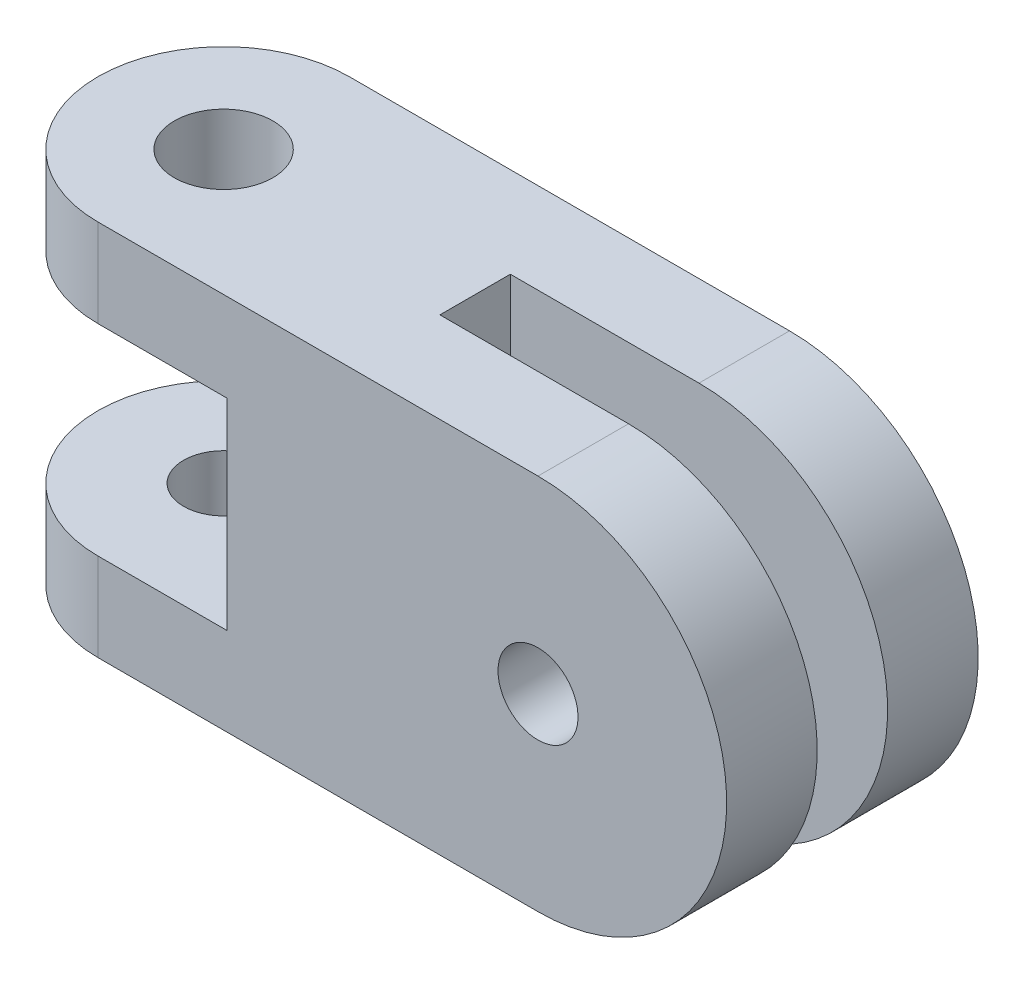
from build123d import *

# Parameters (mm, degrees)
BOSS_EXTRUDE1_DEPTH        = 9.525
BOSS_EXTRUDE2_DEPTH        = 12.7
CUT_EXTRUDE1_DEPTH         = 5.08
F_10_32_TAPPED_HOLE1_D     = 4.0386
F_10_32_TAPPED_HOLE1_DEPTH = 4.445
F_10_CLEARANCE_HOLE1_D     = 4.9784
F_10_CLEARANCE_HOLE1_DEPTH = 14.604
CUT_EXTRUDE2_DEPTH         = 1.778
F_10_CLEARANCE_HOLE2_D     = 4.9784
F_10_CLEARANCE_HOLE2_DEPTH = 8.127
F_10_32_TAPPED_HOLE2_D     = 4.0386


with BuildPart() as part:
    # Sketch1 → Boss-Extrude1 (new, symmetric)
    with BuildSketch(Plane(origin=(0, 0, 0), x_dir=(1, 0, 0), z_dir=(0, 1, 0))):
        with BuildLine():
            Line((0, -6.35), (-15.875, -6.35))
            ThreePointArc((-15.875, -6.35), (-22.225, 0), (-15.875, 6.35))
            Line((-15.875, 6.35), (0, 6.35))
            Line((0, 6.35), (0, -6.35))
        make_face()
    extrude(amount=BOSS_EXTRUDE1_DEPTH, both=True)

    # Sketch2 → Boss-Extrude2 (add)
    with BuildSketch(Plane.XY.offset(6.35)):
        with BuildLine():
            Line((0, 9.525), (6.35, 9.525))
            ThreePointArc((6.35, 9.525), (15.875, 0), (6.35, -9.525))
            Line((6.35, -9.525), (0, -9.525))
            ThreePointArc((0, -9.525), (-9.525, 0), (0, 9.525))
        make_face()
    extrude(amount=-BOSS_EXTRUDE2_DEPTH)

    # Sketch3 → Cut-Extrude1 (cut, symmetric)
    with BuildSketch(Plane(origin=(0, 0, 0), x_dir=(1, 0, 0), z_dir=(0, 1, 0))):
        with BuildLine():
            Line((-9.351499966, 6.35), (-15.875, 6.35))
            ThreePointArc((-15.875, 6.35), (-22.225, 0), (-15.875, -6.35))
            Line((-15.875, -6.35), (-9.351499966, -6.35))
            Line((-9.351499966, -6.35), (-9.351499966, 6.35))
        make_face()
    extrude(amount=CUT_EXTRUDE1_DEPTH, both=True, mode=Mode.SUBTRACT)

    # #10-32 Tapped Hole1
    with Locations(Plane(origin=(0, -5.08, 0), x_dir=(1, 0, 0), z_dir=(0, 1, 0))):
        with Locations((-15.875, 0)):
            Hole(F_10_32_TAPPED_HOLE1_D / 2, depth=F_10_32_TAPPED_HOLE1_DEPTH)

    # #10 Clearance Hole1
    with Locations(Plane(origin=(0, 9.525, 0), x_dir=(1, 0, 0), z_dir=(0, 1, 0))):
        with Locations((-15.875, 0)):
            Hole(F_10_CLEARANCE_HOLE1_D / 2, depth=F_10_CLEARANCE_HOLE1_DEPTH)

    # Sketch9 → Cut-Extrude2 (cut, symmetric)
    with BuildSketch(Plane.XY):
        with BuildLine():
            Line((-3.175, 0), (-3.175, -9.525))
            Line((-3.175, -9.525), (6.35, -9.525))
            ThreePointArc((6.35, -9.525), (15.875, 0), (6.35, 9.525))
            Line((6.35, 9.525), (-3.175, 9.525))
            Line((-3.175, 9.525), (-3.175, 0))
        make_face()
    extrude(amount=CUT_EXTRUDE2_DEPTH, both=True, mode=Mode.SUBTRACT)

    # #10 Clearance Hole2
    with Locations(Plane(origin=(0, 0, -6.35), x_dir=(-1, 0, 0), z_dir=(0, 0, -1))):
        with Locations((-6.35, 0)):
            Hole(F_10_CLEARANCE_HOLE2_D / 2, depth=F_10_CLEARANCE_HOLE2_DEPTH)

    # #10-32 Tapped Hole2 (through all)
    with Locations(Plane(origin=(0, 0, 1.778), x_dir=(-1, 0, 0), z_dir=(0, 0, -1))):
        with Locations((-6.35, 0)):
            Hole(F_10_32_TAPPED_HOLE2_D / 2)


solid = part.part
